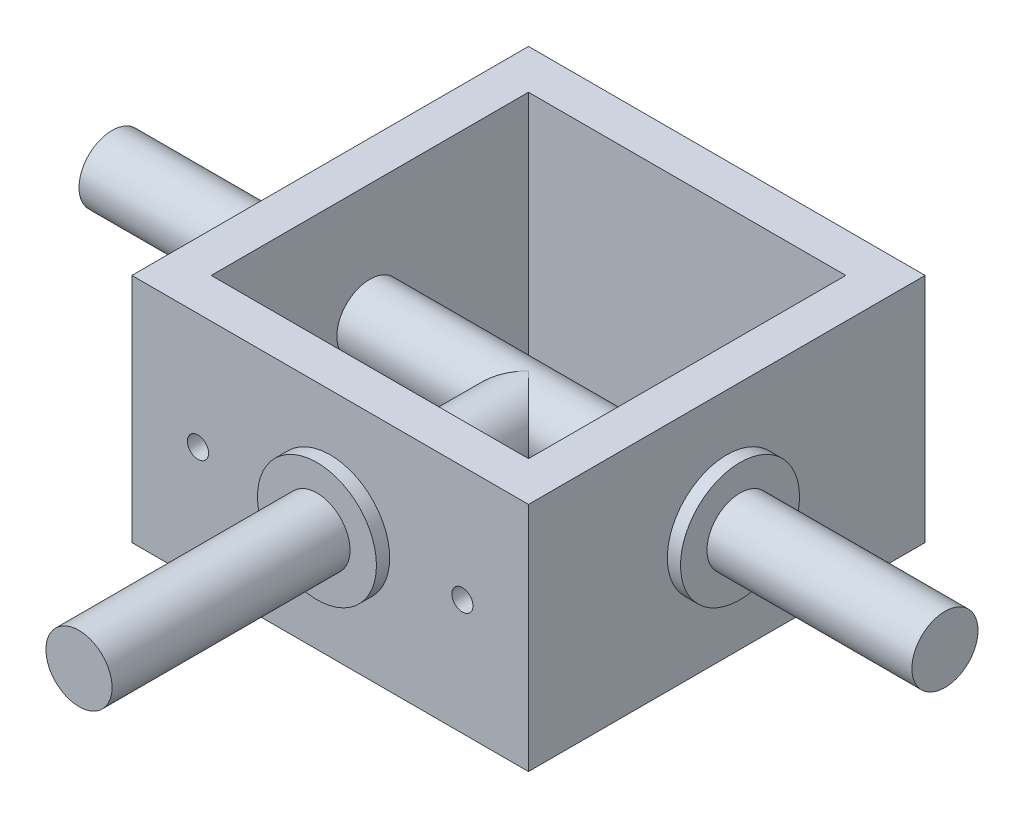
from build123d import *

# Parameters (mm, degrees)
SALIENTE_EXTRUIR1_DEPTH      = 17.5
SALIENTE_EXTRUIR1_DEPTH_BACK = 17.5
CROQUIS1_W                   = 60
CROQUIS1_H                   = 60
CROQUIS1_W_2                 = 48
CROQUIS1_H_2                 = 48
CROQUIS2_R                   = 9
SALIENTE_EXTRUIR2_DEPTH      = 2
CROQUIS3_R                   = 9
SALIENTE_EXTRUIR3_DEPTH      = 2
SALIENTE_EXTRUIR4_START      = 2
CROQUIS4_R                   = 9
SALIENTE_EXTRUIR4_DEPTH      = 2
SALIENTE_EXTRUIR5_DEPTH      = 63
SALIENTE_EXTRUIR5_DEPTH_BACK = 63
CROQUIS5_R                   = 5
CROQUIS6_R                   = 5
SALIENTE_EXTRUIR6_DEPTH      = 68
CUT_EXTRUDE1_REACH           = 90.743
SKETCH1_R                    = 1.6


with BuildPart() as part:
    # Croquis1 → Saliente-Extruir1 (new, two sides: drawn at the far end of the back side and taken through both)
    with BuildSketch(Plane(origin=(0, 0, 0), x_dir=(1, 0, 0), z_dir=(0, 1, 0)).offset(-SALIENTE_EXTRUIR1_DEPTH_BACK)):
        Rectangle(CROQUIS1_W, CROQUIS1_H)
        Rectangle(CROQUIS1_W_2, CROQUIS1_H_2, mode=Mode.SUBTRACT)
    extrude(amount=SALIENTE_EXTRUIR1_DEPTH + SALIENTE_EXTRUIR1_DEPTH_BACK)

    # Croquis2 → Saliente-Extruir2 (add)
    with BuildSketch(Plane.XY.offset(30)):
        Circle(CROQUIS2_R)
    extrude(amount=SALIENTE_EXTRUIR2_DEPTH)

    # Croquis3 → Saliente-Extruir3 (add)
    with BuildSketch(Plane(origin=(30, 0, 0), x_dir=(0, 0, -1), z_dir=(1, 0, 0))):
        Circle(CROQUIS3_R)
    extrude(amount=SALIENTE_EXTRUIR3_DEPTH)

    # Croquis4 → Saliente-Extruir4 (add)
    with BuildSketch(Plane.ZY.offset(30).offset(SALIENTE_EXTRUIR4_START)):
        Circle(CROQUIS4_R)
    extrude(amount=-SALIENTE_EXTRUIR4_DEPTH)

    # Croquis5 → Saliente-Extruir5 (add, two sides: drawn at the far end of the back side and taken through both)
    with BuildSketch(Plane(origin=(0, 0, 0), x_dir=(0, 0, -1), z_dir=(1, 0, 0)).offset(-SALIENTE_EXTRUIR5_DEPTH_BACK)):
        Circle(CROQUIS5_R)
    extrude(amount=SALIENTE_EXTRUIR5_DEPTH + SALIENTE_EXTRUIR5_DEPTH_BACK)

    # Croquis6 → Saliente-Extruir6 (add)
    with BuildSketch(Plane.XY):
        Circle(CROQUIS6_R)
    extrude(amount=SALIENTE_EXTRUIR6_DEPTH)

    # Sketch1 → Cut-Extrude1 (cut, up to next)
    with BuildSketch(Plane.XY.offset(30), mode=Mode.PRIVATE) as cut_extrude1_sk1:
        with Locations((-20, 0)):
            Circle(SKETCH1_R)
    cut_extrude1_tool1 = extrude(cut_extrude1_sk1.sketch, amount=-CUT_EXTRUDE1_REACH, mode=Mode.PRIVATE) & part.part
    # Sketch1 → Cut-Extrude1 (cut, up to next)
    with BuildSketch(Plane.XY.offset(30), mode=Mode.PRIVATE) as cut_extrude1_sk2:
        with Locations((20, 0)):
            Circle(SKETCH1_R)
    cut_extrude1_tool2 = extrude(cut_extrude1_sk2.sketch, amount=-CUT_EXTRUDE1_REACH, mode=Mode.PRIVATE) & part.part
    add(cut_extrude1_tool1.solids().sort_by_distance((-20, 0, 30))[0], mode=Mode.SUBTRACT)
    add(cut_extrude1_tool2.solids().sort_by_distance((20, 0, 30))[0], mode=Mode.SUBTRACT)


solid = part.part
